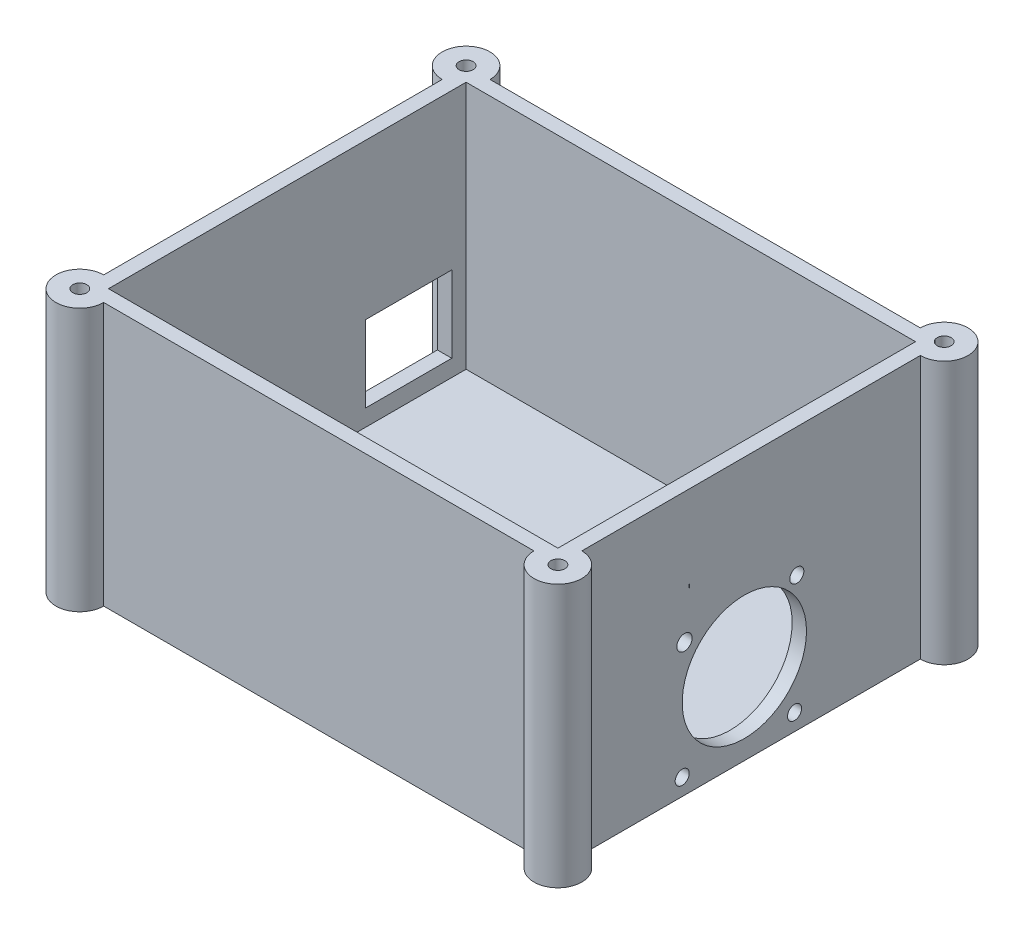
from build123d import *

# Parameters (mm, degrees)
SKETCH1_W           = 100
SKETCH1_H           = 80.8
BOSS_EXTRUDE1_DEPTH = 55
SKETCH2_W           = 94
SKETCH2_H           = 74.8
CUT_EXTRUDE1_DEPTH  = 52
SKETCH3_W           = 18
SKETCH3_H           = 16
CUT_EXTRUDE2_DEPTH  = 3
SKETCH4_W           = 11
SKETCH4_H           = 6
CUT_EXTRUDE3_DEPTH  = 3
SKETCH5_R           = 13
SKETCH5_W           = 0.144392858
SKETCH5_H           = 0.781479989
CUT_EXTRUDE5_DEPTH  = 3
SKETCH7_R           = 1.601751043
SKETCH7_R_2         = 1.47
CUT_EXTRUDE6_DEPTH  = 3
BOSS_EXTRUDE2_DEPTH = 55
BOSS_EXTRUDE3_DEPTH = 55
BOSS_EXTRUDE4_DEPTH = 55
BOSS_EXTRUDE5_DEPTH = 55
SKETCH13_R          = 1.47
CUT_EXTRUDE7_DEPTH  = 55
SKETCH14_R          = 1.47
CUT_EXTRUDE8_DEPTH  = 55
SKETCH15_R          = 1.47
CUT_EXTRUDE9_DEPTH  = 55
SKETCH16_R          = 1.47
CUT_EXTRUDE10_DEPTH = 55


with BuildPart() as part:
    # Sketch1 → Boss-Extrude1 (new body)
    with BuildSketch(Plane(origin=(0, 0, 0), x_dir=(1, 0, 0), z_dir=(0, 1, 0))):
        with Locations((-4.304593931, -21.292828061)):
            Rectangle(SKETCH1_W, SKETCH1_H)
    extrude(amount=BOSS_EXTRUDE1_DEPTH)

    # Sketch2 → Cut-Extrude1 (cut)
    with BuildSketch(Plane(origin=(0, 55, 0), x_dir=(1, 0, 0), z_dir=(0, 1, 0))):
        with Locations((-4.304593931, -21.292828061)):
            Rectangle(SKETCH2_W, SKETCH2_H)
    extrude(amount=-CUT_EXTRUDE1_DEPTH, mode=Mode.SUBTRACT)

    # Sketch3 → Cut-Extrude2 (cut)
    with BuildSketch(Plane.ZY.offset(54.304593931)):
        with Locations((-4.107171939, 14.5)):
            Rectangle(SKETCH3_W, SKETCH3_H)
    extrude(amount=-CUT_EXTRUDE2_DEPTH, mode=Mode.SUBTRACT)

    # Sketch4 → Cut-Extrude3 (cut)
    with BuildSketch(Plane(origin=(0, 0, -19.107171939), x_dir=(-1, 0, 0), z_dir=(0, 0, -1))):
        with Locations((-25.195406069, 9)):
            Rectangle(SKETCH4_W, SKETCH4_H)
    extrude(amount=-CUT_EXTRUDE3_DEPTH, mode=Mode.SUBTRACT)

    # Sketch5 → Cut-Extrude5 (cut)
    with BuildSketch(Plane(origin=(45.695406069, 0, 0), x_dir=(0, 0, -1), z_dir=(1, 0, 0))):
        with Locations((-22.692828061, 17)):
            Circle(SKETCH5_R)
        with Locations((-34.241433139, 37.409557734)):
            Rectangle(SKETCH5_W, SKETCH5_H)
    extrude(amount=-CUT_EXTRUDE5_DEPTH, mode=Mode.SUBTRACT)

    # Sketch7 → Cut-Extrude6 (cut)
    with BuildSketch(Plane(origin=(45.695406069, 0, 0), x_dir=(0, 0, -1), z_dir=(1, 0, 0))):
        with Locations((-35.2122597, 27.701622842)):
            Circle(SKETCH7_R)
        with Locations((-35.692828061, 3.5)):
            Circle(SKETCH7_R_2)
        with Locations((-12.192828061, 3.5)):
            Circle(SKETCH7_R_2)
        with Locations((-11.71600068, 28.120922326)):
            Circle(SKETCH7_R_2)
    extrude(amount=-CUT_EXTRUDE6_DEPTH, mode=Mode.SUBTRACT)

    # Sketch9 → Boss-Extrude2 (add)
    with BuildSketch(Plane(origin=(0, 55, 0), x_dir=(1, 0, 0), z_dir=(0, 1, 0))):
        with BuildLine():
            Line((41.695406069, 16.107171939), (42.695406069, 16.107171939))
            Line((42.695406069, 16.107171939), (42.695406069, 15.107171939))
            ThreePointArc((42.695406069, 15.107171939), (49.230939975, 22.642705845), (41.695406069, 16.107171939))
        make_face()
    extrude(amount=-BOSS_EXTRUDE2_DEPTH)

    # Sketch10 → Boss-Extrude3 (add)
    with BuildSketch(Plane(origin=(0, 55, 0), x_dir=(1, 0, 0), z_dir=(0, 1, 0))):
        with BuildLine():
            Line((-51.304593931, -57.692828061), (-51.304593931, -58.692828061))
            Line((-51.304593931, -58.692828061), (-50.304593931, -58.692828061))
            ThreePointArc((-50.304593931, -58.692828061), (-57.840127837, -65.228361967), (-51.304593931, -57.692828061))
        make_face()
    extrude(amount=-BOSS_EXTRUDE3_DEPTH)

    # Sketch11 → Boss-Extrude4 (add)
    with BuildSketch(Plane(origin=(0, 55, 0), x_dir=(1, 0, 0), z_dir=(0, 1, 0))):
        with BuildLine():
            Line((-50.304593931, 16.107171939), (-51.304593931, 16.107171939))
            Line((-51.304593931, 16.107171939), (-51.304593931, 15.107171939))
            ThreePointArc((-51.304593931, 15.107171939), (-57.840127837, 22.642705845), (-50.304593931, 16.107171939))
        make_face()
    extrude(amount=-BOSS_EXTRUDE4_DEPTH)

    # Sketch12 → Boss-Extrude5 (add)
    with BuildSketch(Plane(origin=(0, 55, 0), x_dir=(1, 0, 0), z_dir=(0, 1, 0))):
        with BuildLine():
            Line((41.695406069, -58.692828061), (42.695406069, -58.692828061))
            Line((42.695406069, -58.692828061), (42.695406069, -57.692828061))
            ThreePointArc((42.695406069, -57.692828061), (49.230939975, -65.228361967), (41.695406069, -58.692828061))
        make_face()
    extrude(amount=-BOSS_EXTRUDE5_DEPTH)

    # Sketch13 → Cut-Extrude7 (cut)
    with BuildSketch(Plane(origin=(0, 55, 0), x_dir=(1, 0, 0), z_dir=(0, 1, 0))):
        with Locations((45.695406069, -61.692828061)):
            Circle(SKETCH13_R)
    extrude(amount=-CUT_EXTRUDE7_DEPTH, mode=Mode.SUBTRACT)

    # Sketch14 → Cut-Extrude8 (cut)
    with BuildSketch(Plane(origin=(0, 55, 0), x_dir=(1, 0, 0), z_dir=(0, 1, 0))):
        with Locations((45.695406069, 19.107171939)):
            Circle(SKETCH14_R)
    extrude(amount=-CUT_EXTRUDE8_DEPTH, mode=Mode.SUBTRACT)

    # Sketch15 → Cut-Extrude9 (cut)
    with BuildSketch(Plane(origin=(0, 55, 0), x_dir=(1, 0, 0), z_dir=(0, 1, 0))):
        with Locations((-54.304593931, 19.107171939)):
            Circle(SKETCH15_R)
    extrude(amount=-CUT_EXTRUDE9_DEPTH, mode=Mode.SUBTRACT)

    # Sketch16 → Cut-Extrude10 (cut)
    with BuildSketch(Plane(origin=(0, 55, 0), x_dir=(1, 0, 0), z_dir=(0, 1, 0))):
        with Locations((-54.304593931, -61.692828061)):
            Circle(SKETCH16_R)
    extrude(amount=-CUT_EXTRUDE10_DEPTH, mode=Mode.SUBTRACT)


solid = part.part
